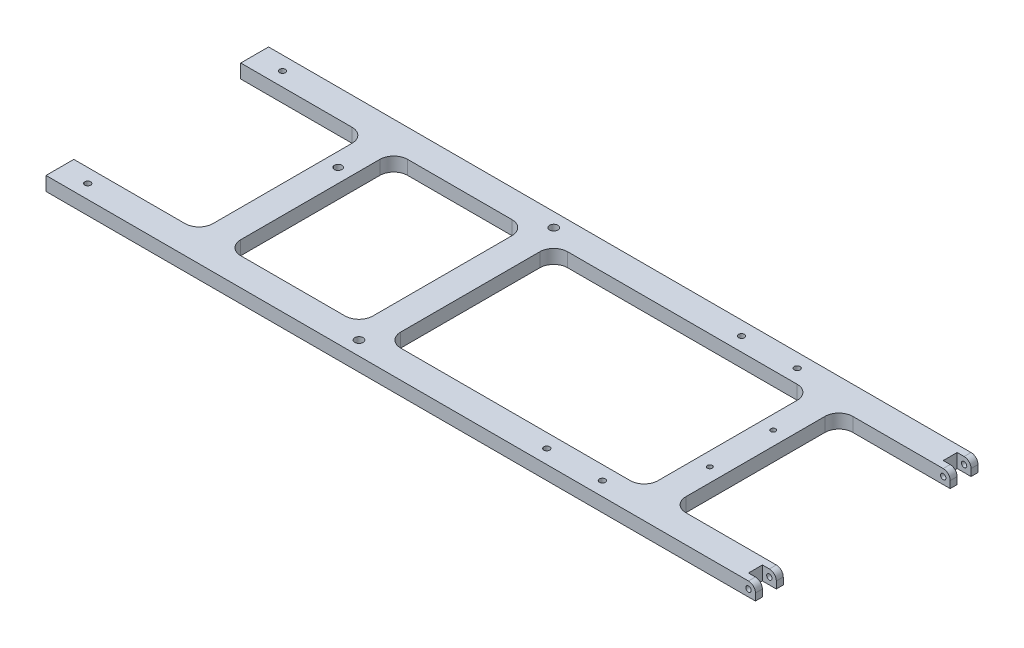
from build123d import *

# Parameters (mm, degrees)
SKETCH1_W                  = 323.85
SKETCH1_H                  = 101.6
EXTRUDE1_DEPTH             = 6.35
SKETCH2_W                  = 57.15
SKETCH2_H                  = 76.2
CUT_EXTRUDE1_DEPTH         = 6.35
SKETCH3_W                  = 60.325
SKETCH3_H                  = 76.2
SKETCH3_W_2                = 50.8
SKETCH3_W_3                = 117.475
CUT_EXTRUDE2_DEPTH         = 6.35
SKETCH4_W                  = 6.35
SKETCH4_H                  = 6.35
CUT_EXTRUDE3_DEPTH         = 6.35
F_2_CLEARANCE_HOLE1_D      = 2.4384
FILLET1_R                  = 3.175
TAP_DRILL_FOR_8_TAP1_D     = 3.4544
TAP_DRILL_FOR_8_TAP1_DEPTH = 12.7
TAP_DRILL_FOR_8_TAP1_TIP   = 1.037806461
F_6_CLEARANCE_HOLE1_D      = 3.7973
F_6_CLEARANCE_HOLE1_DEPTH  = 12.7
F_6_CLEARANCE_HOLE1_TIP    = 1.140824014
TAP_DRILL_FOR_6_TAP1_D     = 2.7051
TAP_DRILL_FOR_6_TAP1_DEPTH = 12.7
TAP_DRILL_FOR_6_TAP1_TIP   = 0.81269403
FILLET2_R                  = 6.35
FILLET3_R                  = 6.35
TAP_DRILL_FOR_6_TAP2_D     = 2.7051
TAP_DRILL_FOR_6_TAP2_DEPTH = 101.6
TAP_DRILL_FOR_6_TAP2_TIP   = 0.81269403
TAP_DRILL_FOR_4_TAP1_D     = 2.2606


with BuildPart() as part:
    # Sketch1 → Extrude1 (new body)
    with BuildSketch(Plane(origin=(0, 0, 0), x_dir=(1, 0, 0), z_dir=(0, 1, 0))):
        Rectangle(SKETCH1_W, SKETCH1_H)
    extrude(amount=EXTRUDE1_DEPTH)

    # Sketch2 → Cut-Extrude1 (cut)
    with BuildSketch(Plane(origin=(0, 6.35, 0), x_dir=(-1, 0, 0), z_dir=(0, 1, 0))):
        with Locations((133.35, 0)):
            Rectangle(SKETCH2_W, SKETCH2_H)
    extrude(amount=-CUT_EXTRUDE1_DEPTH, mode=Mode.SUBTRACT)

    # Sketch3 → Cut-Extrude2 (cut)
    with BuildSketch(Plane(origin=(0, 6.35, 0), x_dir=(-1, 0, 0), z_dir=(0, 1, 0))):
        with Locations((61.9125, 0)):
            Rectangle(SKETCH3_W, SKETCH3_H)
        with Locations((-136.525, 0)):
            Rectangle(SKETCH3_W_2, SKETCH3_H)
        with Locations((-39.6875, 0)):
            Rectangle(SKETCH3_W_3, SKETCH3_H)
    extrude(amount=-CUT_EXTRUDE2_DEPTH, mode=Mode.SUBTRACT)

    # Sketch4 → Cut-Extrude3 (cut)
    with BuildSketch(Plane(origin=(0, 6.35, 0), x_dir=(-1, 0, 0), z_dir=(0, 1, 0))):
        with Locations((-158.75, -44.45)):
            Rectangle(SKETCH4_W, SKETCH4_H)
        with Locations((-158.75, 44.45)):
            Rectangle(SKETCH4_W, SKETCH4_H)
    extrude(amount=-CUT_EXTRUDE3_DEPTH, mode=Mode.SUBTRACT)

    # #2 Clearance Hole1 (through all)
    with Locations(Plane(origin=(158.75, 3.175, 50.8), x_dir=(1, 0, 0), z_dir=(0, 0, 1))):
        with Locations((0, 0)):
            Hole(F_2_CLEARANCE_HOLE1_D / 2)

    # Fillet1
    fillet1_edges = [part.edges().sort_by_distance(p)[0] for p in [
        (161.925, 6.35, 49.2125),
        (161.925, 6.35, -39.6875),
        (161.925, 6.35, -49.2125),
        (161.925, 6.35, 39.6875),
    ]]
    fillet(fillet1_edges, radius=FILLET1_R)

    # Tap Drill for #8 Tap1
    with Locations(Plane(origin=(-98.425, 6.35, -19.05), x_dir=(0, 0, 1), z_dir=(0, 1, 0))):
        with Locations((0, 0)):
            Hole(TAP_DRILL_FOR_8_TAP1_D / 2, depth=TAP_DRILL_FOR_8_TAP1_DEPTH)
            with Locations((0, 0, -(TAP_DRILL_FOR_8_TAP1_DEPTH + TAP_DRILL_FOR_8_TAP1_TIP / 2))):  # 118° drill point
                Cone(0, TAP_DRILL_FOR_8_TAP1_D / 2, TAP_DRILL_FOR_8_TAP1_TIP, mode=Mode.SUBTRACT)

    # #6 Clearance Hole1
    with Locations(Plane(origin=(-25.4, 6.35, -44.45), x_dir=(0, 0, 1), z_dir=(0, 1, 0))):
        with Locations((0, 0), (88.9, 0)):
            Hole(F_6_CLEARANCE_HOLE1_D / 2, depth=F_6_CLEARANCE_HOLE1_DEPTH)
            with Locations((0, 0, -(F_6_CLEARANCE_HOLE1_DEPTH + F_6_CLEARANCE_HOLE1_TIP / 2))):  # 118° drill point
                Cone(0, F_6_CLEARANCE_HOLE1_D / 2, F_6_CLEARANCE_HOLE1_TIP, mode=Mode.SUBTRACT)

    # Tap Drill for #6 Tap1
    with Locations(Plane(origin=(-149.225, 6.35, -44.45), x_dir=(0, 0, 1), z_dir=(0, 1, 0))):
        with Locations((0, 0), (88.9, 0)):
            Hole(TAP_DRILL_FOR_6_TAP1_D / 2, depth=TAP_DRILL_FOR_6_TAP1_DEPTH)
            with Locations((0, 0, -(TAP_DRILL_FOR_6_TAP1_DEPTH + TAP_DRILL_FOR_6_TAP1_TIP / 2))):  # 118° drill point
                Cone(0, TAP_DRILL_FOR_6_TAP1_D / 2, TAP_DRILL_FOR_6_TAP1_TIP, mode=Mode.SUBTRACT)

    # Fillet2
    fillet2_edges = [part.edges().sort_by_distance(p)[0] for p in [
        (-104.775, 3.175, -38.1),
        (-104.775, 3.175, 38.1),
        (-92.075, 3.175, 38.1),
        (-92.075, 3.175, -38.1),
        (-31.75, 3.175, -38.1),
        (-31.75, 3.175, 38.1),
        (111.125, 3.175, 38.1),
        (111.125, 3.175, -38.1),
    ]]
    fillet(fillet2_edges, radius=FILLET2_R)

    # Fillet3
    fillet3_edges = [part.edges().sort_by_distance(p)[0] for p in [
        (-19.05, 3.175, 38.1),
        (-19.05, 3.175, -38.1),
        (98.425, 3.175, -38.1),
        (98.425, 3.175, 38.1),
    ]]
    fillet(fillet3_edges, radius=FILLET3_R)

    # Tap Drill for #6 Tap2
    with Locations(Plane(origin=(60.325, 0, 44.45), x_dir=(0, 0, -1), z_dir=(0, -1, 0))):
        with Locations((0, 0), (0, 25.4), (88.9, 0), (88.9, 25.4)):
            Hole(TAP_DRILL_FOR_6_TAP2_D / 2, depth=TAP_DRILL_FOR_6_TAP2_DEPTH)
            with Locations((0, 0, -(TAP_DRILL_FOR_6_TAP2_DEPTH + TAP_DRILL_FOR_6_TAP2_TIP / 2))):  # 118° drill point
                Cone(0, TAP_DRILL_FOR_6_TAP2_D / 2, TAP_DRILL_FOR_6_TAP2_TIP, mode=Mode.SUBTRACT)

    # Tap Drill for #4 Tap1 (through all)
    with Locations(Plane(origin=(104.775, 6.35, 14.478), x_dir=(0, 0, 1), z_dir=(0, 1, 0))):
        with Locations((0, 0), (-28.956, 0)):
            Hole(TAP_DRILL_FOR_4_TAP1_D / 2)


solid = part.part
